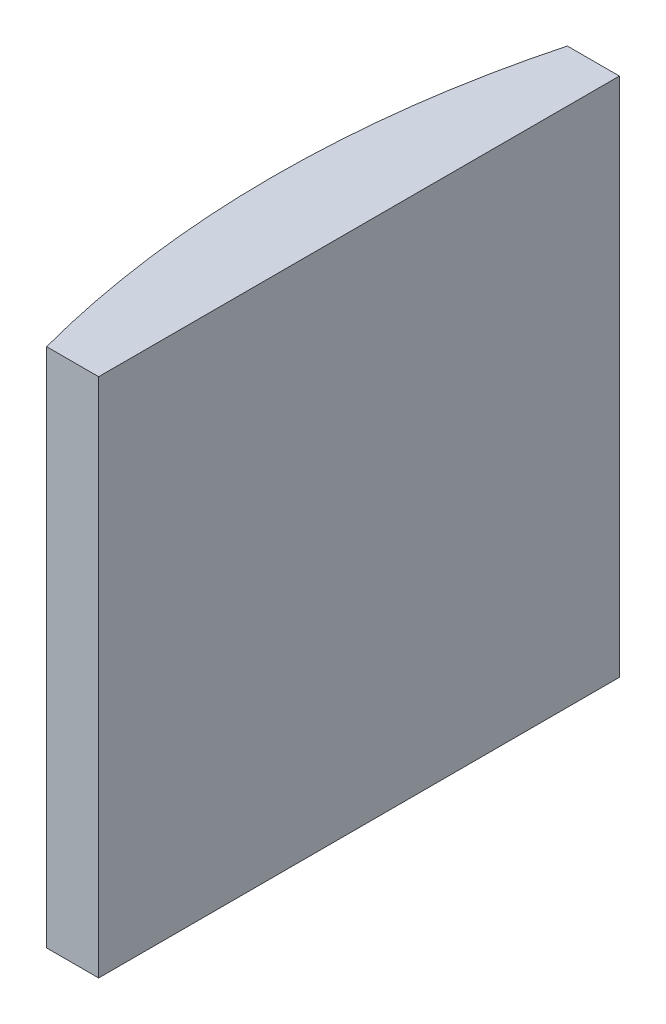
from build123d import *

# Parameters (mm, degrees)
EXTRUDE_1_DEPTH = 20


with BuildPart() as part:
    # 草图1 → 凸台-拉伸1 (new body)
    with BuildSketch(Plane(origin=(0, 0, 0), x_dir=(1, 0, 0), z_dir=(0, 1, 0))):
        with BuildLine():
            Line((-33.113294434, 10), (-31.114795665, 10))
            Line((-31.114795665, 10), (-31.114795665, -10))
            Line((-31.114795665, -10), (-33.113294434, -10))
            ThreePointArc((-33.113294434, -10), (-34.424795665, 0), (-33.113294434, 10))
        make_face()
    extrude(amount=EXTRUDE_1_DEPTH)


solid = part.part
